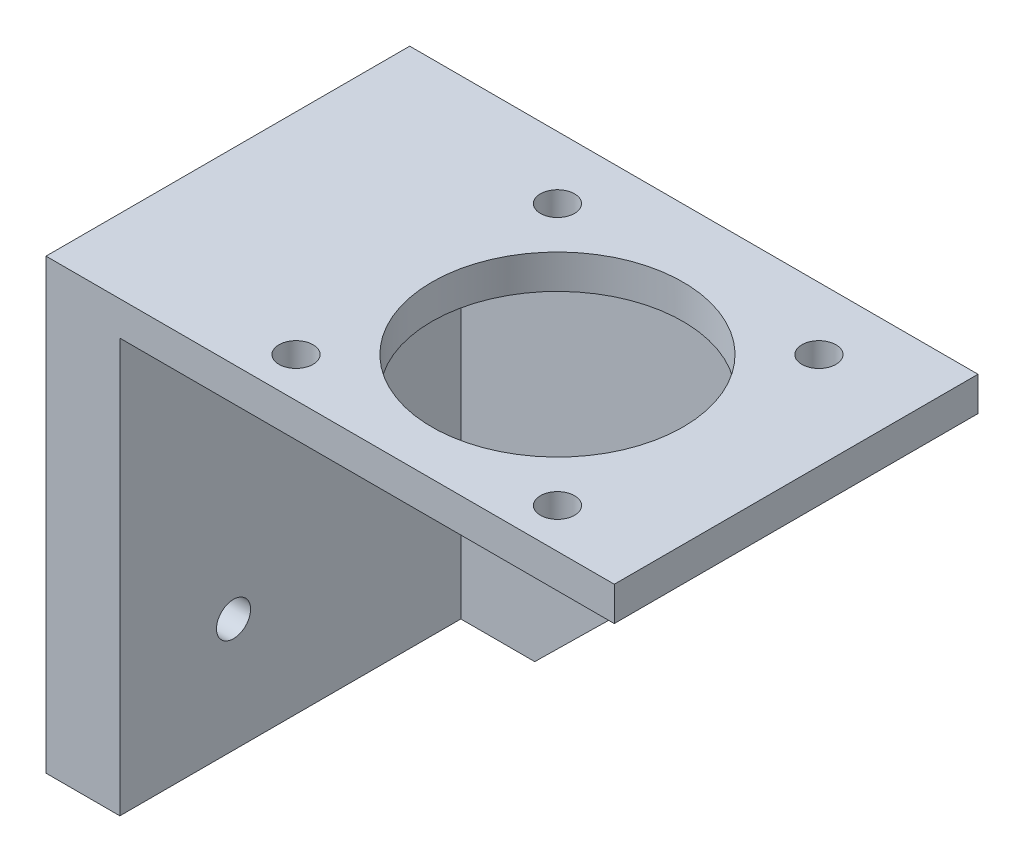
from build123d import *

# Parameters (mm, degrees)
CROQUIS1_W              = 3
CROQUIS1_H              = 36.4
CROQUIS1_H_2            = 3
CROQUIS1_W_2            = 37
SALIENTE_EXTRUIR1_DEPTH = 30
CROQUIS3_R              = 11.05
CROQUIS3_R_2            = 1.5
CORTAR_EXTRUIR2_DEPTH   = 30
SALIENTE_EXTRUIR3_DEPTH = 2
CROQUIS8_W              = 32
CROQUIS8_H              = 39.4
SALIENTE_EXTRUIR4_DEPTH = 10
CROQUIS9_W              = 6.5
CROQUIS9_H              = 36.4
CORTAR_EXTRUIR4_DEPTH   = 30
CROQUIS10_R             = 1.5
CORTAR_EXTRUIR5_DEPTH   = 10


with BuildPart() as part:
    # Croquis1 → Saliente-Extruir1 (new body)
    with BuildSketch(Plane.XY):
        with Locations((0, -1.5)):
            Rectangle(CROQUIS1_W, CROQUIS1_H)
        with Locations((0, 18.2)):
            Rectangle(CROQUIS1_W, CROQUIS1_H_2)
        with Locations((20, 18.2)):
            Rectangle(CROQUIS1_W_2, CROQUIS1_H_2)
    extrude(amount=SALIENTE_EXTRUIR1_DEPTH)

    # Croquis3 → Cortar-Extruir2 (cut)
    with BuildSketch(Plane(origin=(0, 19.7, 0), x_dir=(1, 0, 0), z_dir=(0, 1, 0))):
        with Locations((18.5, -15)):
            Circle(CROQUIS3_R)
        with Locations((6.997816512, -26.5)):
            Circle(CROQUIS3_R_2)
        with Locations((30.002183488, -26.5)):
            Circle(CROQUIS3_R_2)
        with Locations((30.002183488, -3.5)):
            Circle(CROQUIS3_R_2)
        with Locations((6.997816512, -3.5)):
            Circle(CROQUIS3_R_2)
    extrude(amount=-CORTAR_EXTRUIR2_DEPTH, mode=Mode.SUBTRACT)

    # Croquis6 → Saliente-Extruir3 (add)
    with BuildSketch(Plane.XY):
        Polygon((-1.5, 19.7), (38.5, 19.7), (38.5, 16.7), (1.5, -19.7), (-1.5, -19.7), align=None)
    extrude(amount=-SALIENTE_EXTRUIR3_DEPTH)

    # Croquis8 → Saliente-Extruir4 (add)
    with BuildSketch(Plane.ZY.offset(1.5)):
        with Locations((14, 0)):
            Rectangle(CROQUIS8_W, CROQUIS8_H)
    extrude(amount=SALIENTE_EXTRUIR4_DEPTH)

    # Croquis9 → Cortar-Extruir4 (cut)
    with BuildSketch(Plane.XY.offset(30)):
        with Locations((-1.75, -1.5)):
            Rectangle(CROQUIS9_W, CROQUIS9_H)
    extrude(amount=-CORTAR_EXTRUIR4_DEPTH, mode=Mode.SUBTRACT)

    # Croquis10 → Cortar-Extruir5 (cut)
    with BuildSketch(Plane.ZY.offset(11.5)):
        with Locations((5, 14.7)):
            Circle(CROQUIS10_R)
        with Locations((20, 14.7)):
            Circle(CROQUIS10_R)
        with Locations((20, -9.7)):
            Circle(CROQUIS10_R)
    extrude(amount=-CORTAR_EXTRUIR5_DEPTH, mode=Mode.SUBTRACT)


solid = part.part
